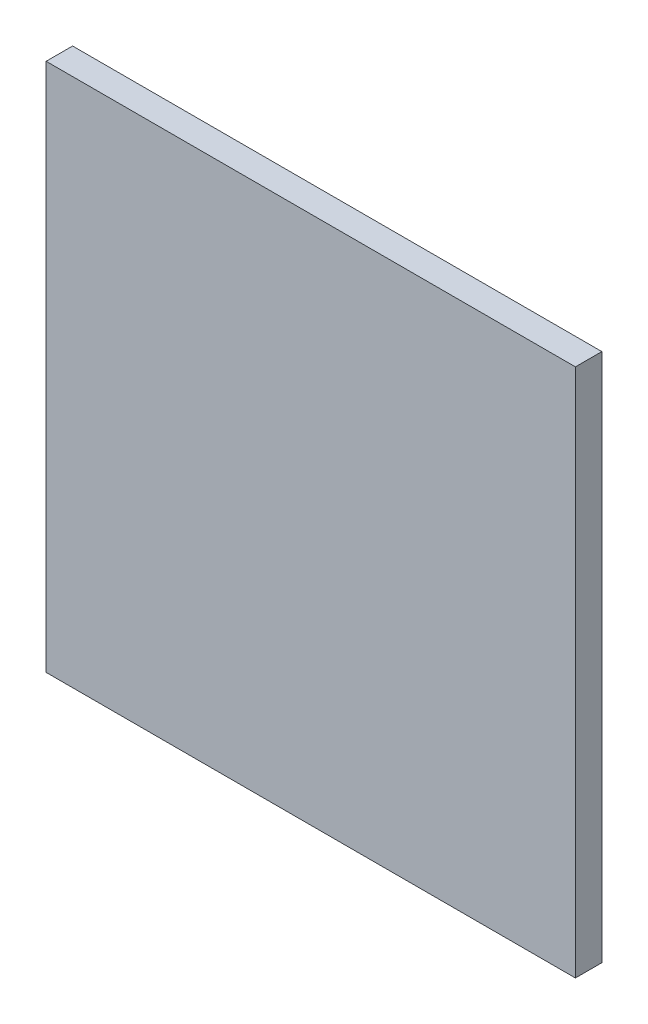
from build123d import *

# Parameters (mm, degrees)
SKETCH1_W           = 5000
SKETCH1_H           = 5000
BOSS_EXTRUDE1_DEPTH = 250


with BuildPart() as part:
    # Sketch1 → Boss-Extrude1 (new body)
    with BuildSketch(Plane.XY):
        Rectangle(SKETCH1_W, SKETCH1_H)
    extrude(amount=BOSS_EXTRUDE1_DEPTH)


solid = part.part
